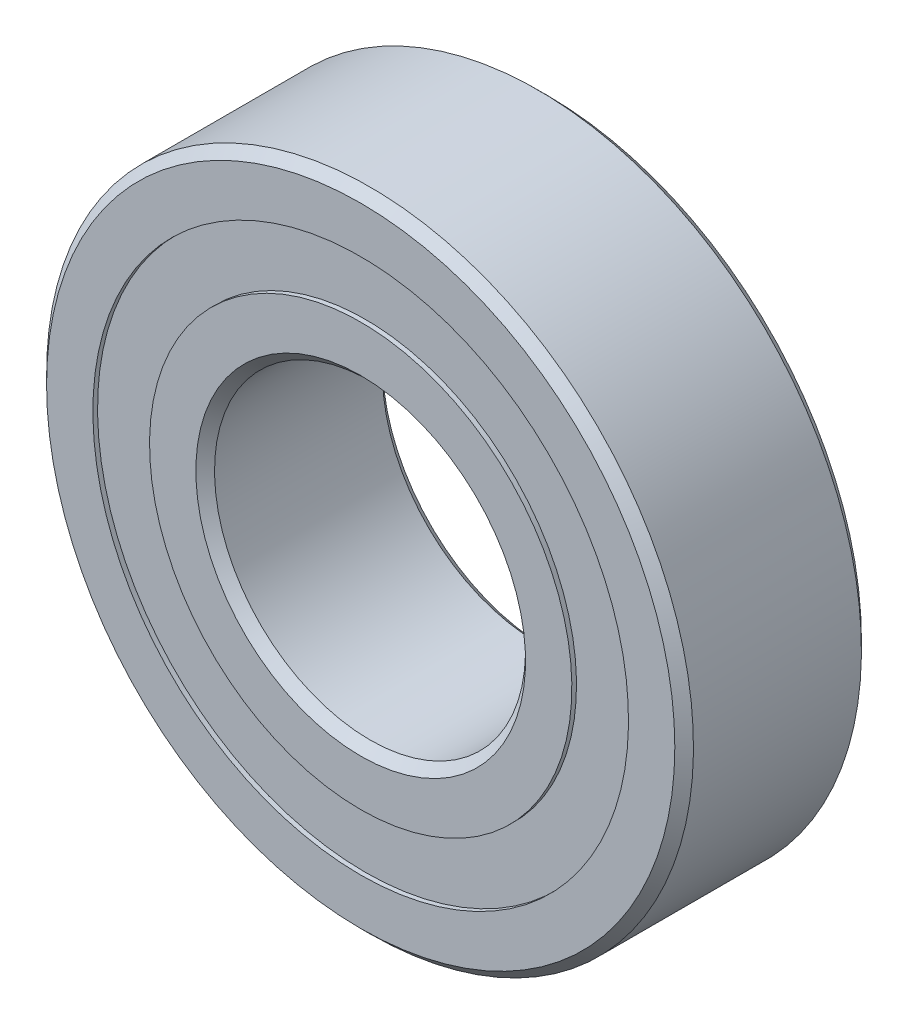
from build123d import *

# Parameters (mm, degrees)
CIRPATTERN1_COUNT = 9
SKETCH5_W         = 3.088232753
SKETCH5_H         = 4.553846154


with BuildPart() as part:
    # Sketch7 → Revolve6 (revolve)
    with BuildSketch(Plane(origin=(0, 0, 0), x_dir=(0, 0, -1), z_dir=(1, 0, 0))):
        with BuildLine():
            Line((6.75, 26), (7.5, 25.25))
            Line((7.5, 25.25), (7.5, 21.526923077))
            Line((7.5, 21.526923077), (3.333333333, 21.526923077))
            ThreePointArc((3.333333333, 21.526923077), (0, 23.286767247), (-3.333333333, 21.526923077))
            Line((-3.333333333, 21.526923077), (-7.5, 21.526923077))
            Line((-7.5, 21.526923077), (-7.5, 25.25))
            Line((-7.5, 25.25), (-6.75, 26))
            Line((-6.75, 26), (6.75, 26))
        make_face()
    revolve(axis=Axis((0, 0, 7.5), (0, 0, -1)))


with BuildPart() as body_2:
    # Sketch3 → Revolve3 (revolve)
    with BuildSketch(Plane(origin=(0, 0, 0), x_dir=(0, 0, -1), z_dir=(1, 0, 0))):
        with BuildLine():
            Line((-6.75, 12.5), (-7.5, 13.25))
            Line((-7.5, 13.25), (-7.5, 16.973076923))
            Line((-7.5, 16.973076923), (-3.333333333, 16.973076923))
            ThreePointArc((-3.333333333, 16.973076923), (0, 15.213232753), (3.333333333, 16.973076923))
            Line((3.333333333, 16.973076923), (7.5, 16.973076923))
            Line((7.5, 16.973076923), (7.5, 13.25))
            Line((7.5, 13.25), (6.75, 12.5))
            Line((6.75, 12.5), (-6.75, 12.5))
        make_face()
    revolve(axis=Axis((0, 0, 7.5), (0, 0, -1)))


with BuildPart() as body_3:
    # Sketch4 → Revolve4 (revolve)
    with BuildSketch(Plane(origin=(0, 0, 0), x_dir=(0, 0, -1), z_dir=(1, 0, 0))):
        with BuildLine():
            Line((-4.036767247, 19.25), (4.036767247, 19.25))
            ThreePointArc((4.036767247, 19.25), (0, 23.286767247), (-4.036767247, 19.25))
        make_face()
    revolve(axis=Axis((0, 19.25, 4.036767247), (0, 0, -1)))


with BuildPart() as cirpattern1_1:
    # CirPattern1: pattern copy
    add(body_3.part.rotate(Axis((0, 0, 0), (0, 0, 1)), 1 * 360 / CIRPATTERN1_COUNT))


with BuildPart() as cirpattern1_2:
    # CirPattern1: pattern copy
    add(body_3.part.rotate(Axis((0, 0, 0), (0, 0, 1)), 2 * 360 / CIRPATTERN1_COUNT))


with BuildPart() as cirpattern1_3:
    # CirPattern1: pattern copy
    add(body_3.part.rotate(Axis((0, 0, 0), (0, 0, 1)), 3 * 360 / CIRPATTERN1_COUNT))


with BuildPart() as cirpattern1_4:
    # CirPattern1: pattern copy
    add(body_3.part.rotate(Axis((0, 0, 0), (0, 0, 1)), 4 * 360 / CIRPATTERN1_COUNT))


with BuildPart() as cirpattern1_5:
    # CirPattern1: pattern copy
    add(body_3.part.rotate(Axis((0, 0, 0), (0, 0, 1)), 5 * 360 / CIRPATTERN1_COUNT))


with BuildPart() as cirpattern1_6:
    # CirPattern1: pattern copy
    add(body_3.part.rotate(Axis((0, 0, 0), (0, 0, 1)), 6 * 360 / CIRPATTERN1_COUNT))


with BuildPart() as cirpattern1_7:
    # CirPattern1: pattern copy
    add(body_3.part.rotate(Axis((0, 0, 0), (0, 0, 1)), 7 * 360 / CIRPATTERN1_COUNT))


with BuildPart() as cirpattern1_8:
    # CirPattern1: pattern copy
    add(body_3.part.rotate(Axis((0, 0, 0), (0, 0, 1)), 8 * 360 / CIRPATTERN1_COUNT))


with BuildPart() as body_12:
    # Sketch5 → Revolve5 (revolve)
    with BuildSketch(Plane(origin=(0, 0, 0), x_dir=(0, 0, -1), z_dir=(1, 0, 0))):
        with Locations((-5.580883624, 19.25)):
            Rectangle(SKETCH5_W, SKETCH5_H)
        with Locations((5.580883624, 19.25)):
            Rectangle(SKETCH5_W, SKETCH5_H)
    revolve(axis=Axis((0, 0, 7.5), (0, 0, -1)))


solid = Compound([part.part, body_2.part, body_3.part, cirpattern1_1.part, cirpattern1_2.part, cirpattern1_3.part, cirpattern1_4.part, cirpattern1_5.part, cirpattern1_6.part, cirpattern1_7.part, cirpattern1_8.part, body_12.part])
